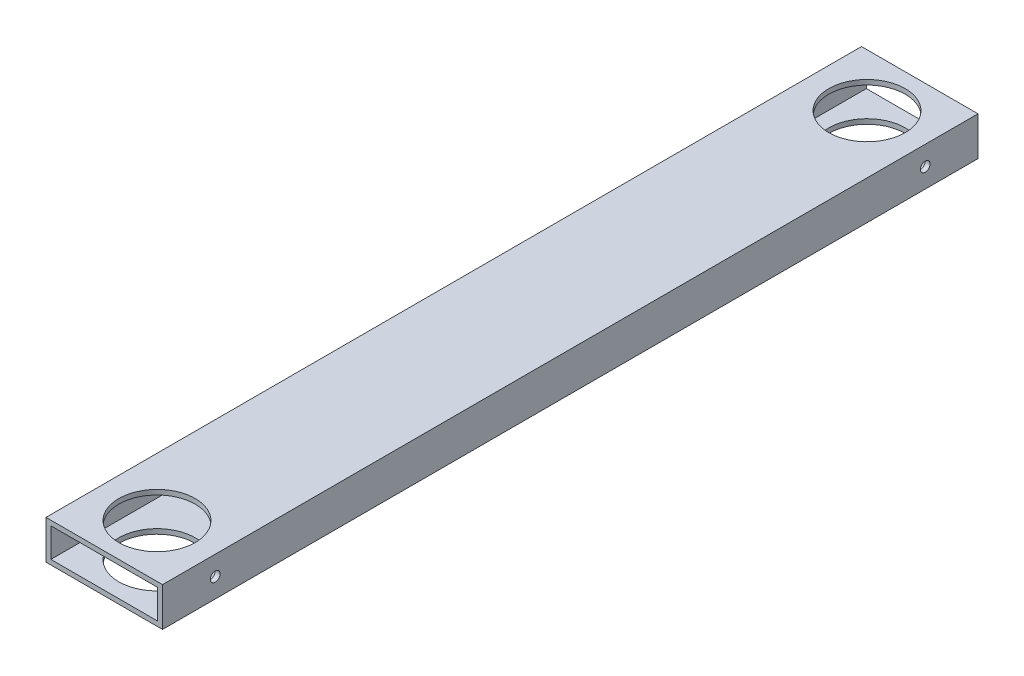
from build123d import *

# Parameters (mm, degrees)
SKETCH1_W           = 76.2
SKETCH1_H           = 25.4
SKETCH1_W_2         = 69.85
SKETCH1_H_2         = 19.05
EXTRUDE_THIN1_DEPTH = 533.4
SKETCH3_R           = 24.97201
CUT_EXTRUDE2_DEPTH  = 26.4
SKETCH4_R           = 3.175
CUT_EXTRUDE3_DEPTH  = 77.2


with BuildPart() as part:
    # Sketch1 → Extrude-Thin1 (new body)
    with BuildSketch(Plane.XY):
        Rectangle(SKETCH1_W, SKETCH1_H)
        Rectangle(SKETCH1_W_2, SKETCH1_H_2, mode=Mode.SUBTRACT)
    extrude(amount=EXTRUDE_THIN1_DEPTH)

    # Sketch3 → Cut-Extrude2 (cut, through all)
    with BuildSketch(Plane(origin=(0, 12.7, 0), x_dir=(1, 0, 0), z_dir=(0, 1, 0))):
        with Locations((0, -34.49701)):
            Circle(SKETCH3_R)
        with Locations((0, -498.90299)):
            Circle(SKETCH3_R)
    extrude(amount=-CUT_EXTRUDE2_DEPTH, mode=Mode.SUBTRACT)

    # Sketch4 → Cut-Extrude3 (cut, through all)
    with BuildSketch(Plane(origin=(38.1, 0, 0), x_dir=(0, 0, -1), z_dir=(1, 0, 0))):
        with Locations((-34.49701, 0)):
            Circle(SKETCH4_R)
        with Locations((-498.90299, 0)):
            Circle(SKETCH4_R)
    extrude(amount=-CUT_EXTRUDE3_DEPTH, mode=Mode.SUBTRACT)


solid = part.part
